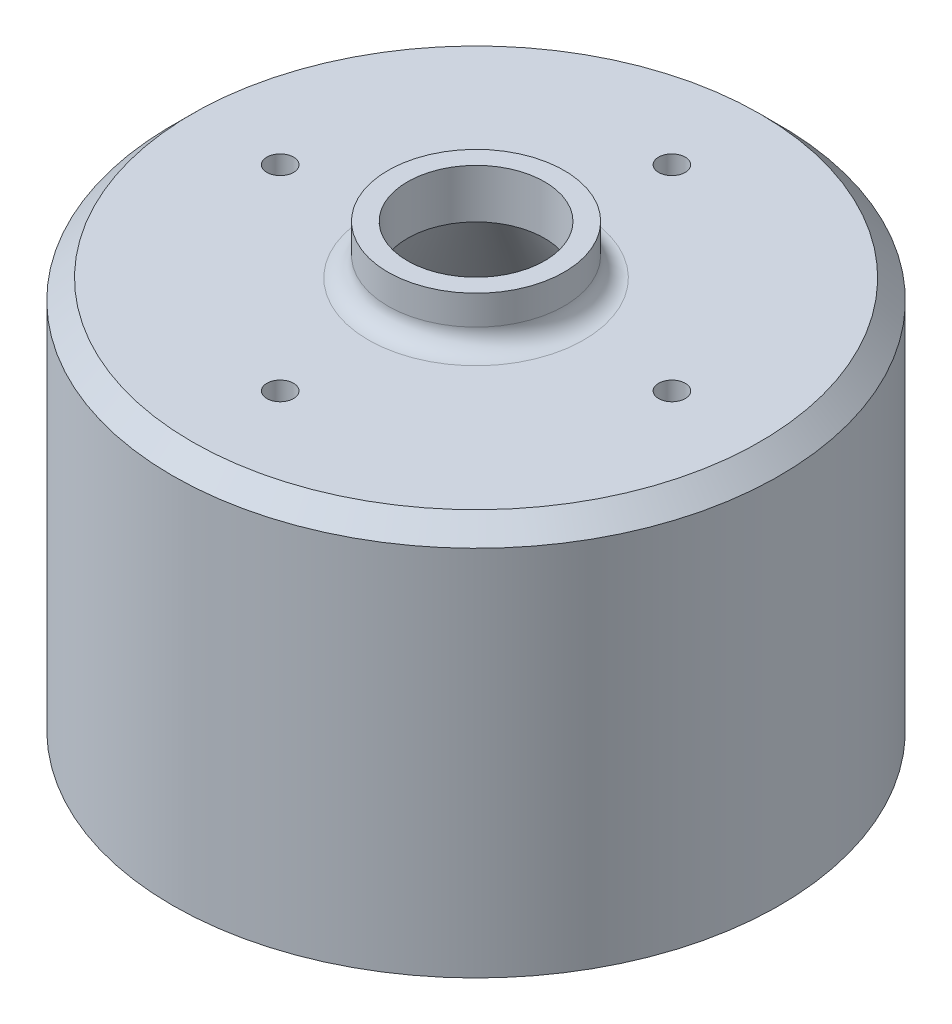
from build123d import *

# Parameters (mm, degrees)
FILLET1_R                 = 2.54
CHAMFER1_SIZE             = 2.54
F_8_32_TAPPED_HOLE1_D     = 3.4544
F_8_32_TAPPED_HOLE1_DEPTH = 10.668
F_8_32_TAPPED_HOLE1_TIP   = 1.037806461


with BuildPart() as part:
    # Sketch1 → Revolve1 (revolve)
    with BuildSketch(Plane.XY):
        Polygon((-8.89, 26.005455731), (-8.89, 19.655455731), (-38.219393675, -31.144544269), (-39.37, -31.144544269), (-39.37, 19.655455731), (-11.43, 19.655455731), (-11.43, 26.005455731), align=None)
    revolve(axis=Axis((0, 33.494633817, 0), (0, -1, 0)))

    # Fillet1
    fillet1_edges = [part.edges().sort_by_distance(p)[0] for p in [
        (11.43, 19.655455731, 0),
    ]]
    fillet(fillet1_edges, radius=FILLET1_R)

    # Chamfer1
    chamfer1_edges = [part.edges().sort_by_distance(p)[0] for p in [
        (39.37, 19.655455731, 0),
    ]]
    chamfer(chamfer1_edges, length=CHAMFER1_SIZE)

    # #8-32 Tapped Hole1
    with Locations(Plane(origin=(0, 19.655455731, 0), x_dir=(1, 0, 0), z_dir=(0, 1, 0))):
        with Locations((0, -25.4), (25.4, 0), (0, 25.4), (-25.4, 0)):
            Hole(F_8_32_TAPPED_HOLE1_D / 2, depth=F_8_32_TAPPED_HOLE1_DEPTH)
            with Locations((0, 0, -(F_8_32_TAPPED_HOLE1_DEPTH + F_8_32_TAPPED_HOLE1_TIP / 2))):  # 118° drill point
                Cone(0, F_8_32_TAPPED_HOLE1_D / 2, F_8_32_TAPPED_HOLE1_TIP, mode=Mode.SUBTRACT)


solid = part.part
